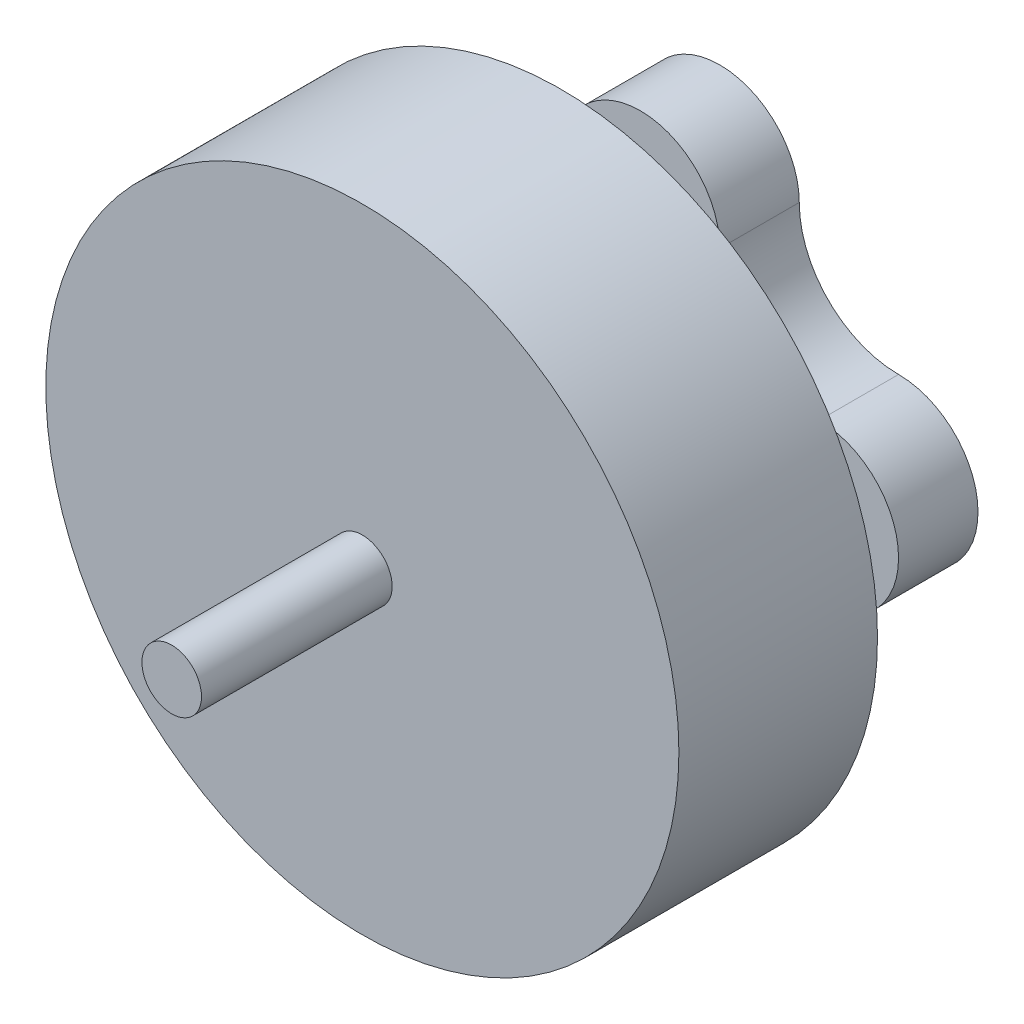
from build123d import *

# Parameters (mm, degrees)
SKETCH1_R           = 7.97
MOTOR_DEPTH         = 5
SHAFT_FOR_PROP_R    = 0.75
BOSS_EXTRUDE2_DEPTH = 4.8
SKETCH3_R           = 2.5
BOSS_EXTRUDE3_DEPTH = 2
SKETCH5_R           = 1
BOSS_EXTRUDE4_DEPTH = 2


with BuildPart() as part:
    # Sketch1 → motor (new body)
    with BuildSketch(Plane.XY):
        Circle(SKETCH1_R)
    extrude(amount=MOTOR_DEPTH)

    # shaft for prop → Boss-Extrude2 (add)
    with BuildSketch(Plane.XY.offset(5)):
        Circle(SHAFT_FOR_PROP_R)
    extrude(amount=BOSS_EXTRUDE2_DEPTH)

    # Sketch3 → Boss-Extrude3 (add)
    with BuildSketch(Plane(origin=(0, 0, 0), x_dir=(-1, 0, 0), z_dir=(0, 0, -1))):
        Circle(SKETCH3_R)
    extrude(amount=BOSS_EXTRUDE3_DEPTH)

    # Sketch5 → Boss-Extrude4 (add)
    with BuildSketch(Plane(origin=(0, 0, -2), x_dir=(-1, 0, 0), z_dir=(0, 0, -1))):
        with BuildLine():
            ThreePointArc((-4.5, 2), (-6.5, 0), (-4.5, -2))
            ThreePointArc((-4.5, -2), (-2.732233047, -2.732233047), (-2, -4.5))
            ThreePointArc((-2, -4.5), (0, -6.5), (2, -4.5))
            ThreePointArc((2, -4.5), (2.732233047, -2.732233047), (4.5, -2))
            ThreePointArc((4.5, -2), (6.5, 0), (4.5, 2))
            ThreePointArc((4.5, 2), (2.732233047, 2.732233047), (2, 4.5))
            ThreePointArc((2, 4.5), (0, 6.5), (-2, 4.5))
            ThreePointArc((-2, 4.5), (-2.732233047, 2.732233047), (-4.5, 2))
        make_face()
        with Locations((4.5, 0)):
            Circle(SKETCH5_R, mode=Mode.SUBTRACT)
        with Locations((-4.5, 0)):
            Circle(SKETCH5_R, mode=Mode.SUBTRACT)
        with Locations((0, -4.5)):
            Circle(SKETCH5_R, mode=Mode.SUBTRACT)
        with Locations((0, 4.5)):
            Circle(SKETCH5_R, mode=Mode.SUBTRACT)
    extrude(amount=BOSS_EXTRUDE4_DEPTH)


solid = part.part
